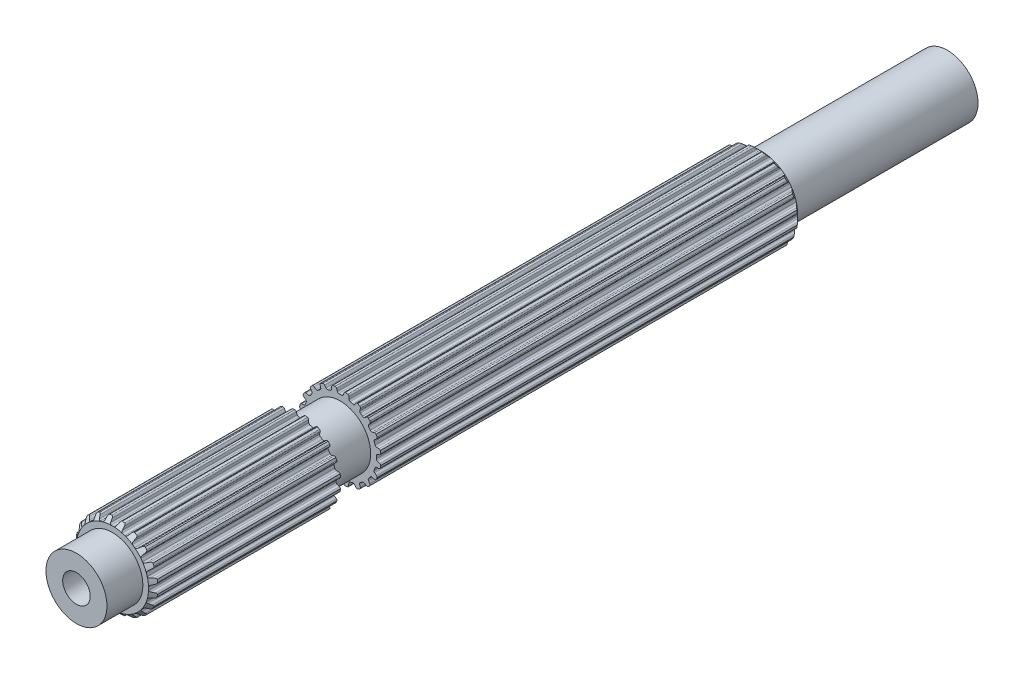
from build123d import *

# Parameters (mm, degrees)
BOSS_EXTRUDE1_DEPTH            = 15.38224
BOSS_EXTRUDE1_DEPTH_BACK       = 37.846
SKETCH2_R                      = 2.5019
BOSS_EXTRUDE2_DEPTH            = 18.32864
BOSS_EXTRUDE2_DEPTH_BACK       = 53.1114
CUT_EXTRUDE1_REACH             = 20.329
SKETCH7_R                      = 1.1303
CUT_EXTRUDE1_DIRECTION_2_REACH = 55.111
SKETCH8_R                      = 1.1303
BOSS_EXTRUDE3_DEPTH            = 8.80364
BOSS_EXTRUDE3_DEPTH_BACK       = 43.5864
SKETCH9_R                      = 6.787859549
SKETCH9_R_2                    = 2.5019
CUT_EXTRUDE2_DEPTH             = 3.302


with BuildPart() as part:
    # Sketch1 → Boss-Extrude1 (new body, two sides)
    with BuildSketch(Plane.XY) as boss_extrude1_sk:
        with BuildLine():
            Line((-0.106949245, 2.969874934), (0.106949245, 2.969874934))
            ThreePointArc((0.106949245, 2.969874934), (0.196343213, 2.986924176), (0.253739238, 3.057547504))
            Line((0.253739238, 3.057547504), (0.315888147, 3.237526941))
            ThreePointArc((0.315888147, 3.237526941), (0.359032156, 3.298322911), (0.4281449, 3.326269005))
            Line((0.4281449, 3.326269005), (0.620027588, 3.2937547))
            ThreePointArc((0.620027588, 3.2937547), (0.689621142, 3.24802576), (0.718272212, 3.169836791))
            Line((0.718272212, 3.169836791), (0.724389167, 2.979527391))
            ThreePointArc((0.724389167, 2.979527391), (0.750934762, 2.9040661), (0.816027049, 2.857568043))
            Line((0.816027049, 2.857568043), (1.019456602, 2.791469774))
            ThreePointArc((1.019456602, 2.791469774), (1.109743823, 2.780060312), (1.186154496, 2.829490741))
            Line((1.186154496, 2.829490741), (1.300878326, 2.981456288))
            ThreePointArc((1.300878326, 2.981456288), (1.360697704, 3.02594446), (1.435063648, 3.031165762))
            Line((1.435063648, 3.031165762), (1.607507455, 2.940947809))
            ThreePointArc((1.607507455, 2.940947809), (1.659563839, 2.875951412), (1.662650905, 2.792735615))
            Line((1.662650905, 2.792735615), (1.609659636, 2.609850378))
            ThreePointArc((1.609659636, 2.609850378), (1.611587176, 2.529879385), (1.659124931, 2.465542482))
            Line((1.659124931, 2.465542482), (1.832172444, 2.339816104))
            ThreePointArc((1.832172444, 2.339816104), (1.914514976, 2.301064775), (2.002460687, 2.32446371))
            Line((2.002460687, 2.32446371), (2.158529469, 2.433539921))
            ThreePointArc((2.158529469, 2.433539921), (2.229168681, 2.457365482), (2.301508367, 2.439350895))
            Line((2.301508367, 2.439350895), (2.437633293, 2.300260456))
            ThreePointArc((2.437633293, 2.300260456), (2.467056864, 2.222358901), (2.444277744, 2.14226202))
            Line((2.444277744, 2.14226202), (2.337365406, 1.984703026))
            ThreePointArc((2.337365406, 1.984703026), (2.314486209, 1.908050449), (2.339816104, 1.832172444))
            Line((2.339816104, 1.832172444), (2.465542482, 1.659124931))
            ThreePointArc((2.465542482, 1.659124931), (2.531880064, 1.596824985), (2.622752074, 1.591901975))
            Line((2.622752074, 1.591901975), (2.804888709, 1.64741171))
            ThreePointArc((2.804888709, 1.64741171), (2.879433095, 1.648242449), (2.942665411, 1.608755366))
            Line((2.942665411, 1.608755366), (3.0291466, 1.434407582))
            ThreePointArc((3.0291466, 1.434407582), (3.033057175, 1.351226417), (2.986641646, 1.282088892))
            Line((2.986641646, 1.282088892), (2.836273564, 1.165279113))
            ThreePointArc((2.836273564, 1.165279113), (2.790827206, 1.099448241), (2.791469774, 1.019456602))
            Line((2.791469774, 1.019456602), (2.857568043, 0.816027049))
            ThreePointArc((2.857568043, 0.816027049), (2.901407091, 0.736276839), (2.986310214, 0.703513784))
            Line((2.986310214, 0.703513784), (3.1766859, 0.700023363))
            ThreePointArc((3.1766859, 0.700023363), (3.247838536, 0.677777961), (3.295773863, 0.620683653))
            Line((3.295773863, 0.620683653), (3.324145932, 0.4281449))
            ThreePointArc((3.324145932, 0.4281449), (3.302160717, 0.347826477), (3.236652255, 0.29641597))
            Line((3.236652255, 0.29641597), (3.057547504, 0.231789562))
            ThreePointArc((3.057547504, 0.231789562), (2.993982591, 0.183224379), (2.969874934, 0.106949245))
            Line((2.969874934, 0.106949245), (2.969874934, -0.106949245))
            ThreePointArc((2.969874934, -0.106949245), (2.986924176, -0.196343213), (3.057547504, -0.253739238))
            Line((3.057547504, -0.253739238), (3.237526941, -0.315888147))
            ThreePointArc((3.237526941, -0.315888147), (3.298322911, -0.359032156), (3.326269005, -0.4281449))
            Line((3.326269005, -0.4281449), (3.2937547, -0.620027588))
            ThreePointArc((3.2937547, -0.620027588), (3.24802576, -0.689621142), (3.169836791, -0.718272212))
            Line((3.169836791, -0.718272212), (2.979527391, -0.724389167))
            ThreePointArc((2.979527391, -0.724389167), (2.9040661, -0.750934762), (2.857568043, -0.816027049))
            Line((2.857568043, -0.816027049), (2.791469774, -1.019456602))
            ThreePointArc((2.791469774, -1.019456602), (2.780060312, -1.109743823), (2.829490741, -1.186154496))
            Line((2.829490741, -1.186154496), (2.981456288, -1.300878326))
            ThreePointArc((2.981456288, -1.300878326), (3.02594446, -1.360697704), (3.031165762, -1.435063648))
            Line((3.031165762, -1.435063648), (2.940947809, -1.607507455))
            ThreePointArc((2.940947809, -1.607507455), (2.875951412, -1.659563839), (2.792735615, -1.662650905))
            Line((2.792735615, -1.662650905), (2.609850378, -1.609659636))
            ThreePointArc((2.609850378, -1.609659636), (2.529879385, -1.611587176), (2.465542482, -1.659124931))
            Line((2.465542482, -1.659124931), (2.339816104, -1.832172444))
            ThreePointArc((2.339816104, -1.832172444), (2.301064775, -1.914514976), (2.32446371, -2.002460687))
            Line((2.32446371, -2.002460687), (2.433539921, -2.158529469))
            ThreePointArc((2.433539921, -2.158529469), (2.457365482, -2.229168681), (2.439350895, -2.301508367))
            Line((2.439350895, -2.301508367), (2.300260456, -2.437633293))
            ThreePointArc((2.300260456, -2.437633293), (2.222358901, -2.467056864), (2.14226202, -2.444277744))
            Line((2.14226202, -2.444277744), (1.984703026, -2.337365406))
            ThreePointArc((1.984703026, -2.337365406), (1.908050449, -2.314486209), (1.832172444, -2.339816104))
            Line((1.832172444, -2.339816104), (1.659124931, -2.465542482))
            ThreePointArc((1.659124931, -2.465542482), (1.596824985, -2.531880064), (1.591901975, -2.622752074))
            Line((1.591901975, -2.622752074), (1.64741171, -2.804888709))
            ThreePointArc((1.64741171, -2.804888709), (1.648242449, -2.879433095), (1.608755366, -2.942665411))
            Line((1.608755366, -2.942665411), (1.434407582, -3.0291466))
            ThreePointArc((1.434407582, -3.0291466), (1.351226417, -3.033057175), (1.282088892, -2.986641646))
            Line((1.282088892, -2.986641646), (1.165279113, -2.836273564))
            ThreePointArc((1.165279113, -2.836273564), (1.099448241, -2.790827206), (1.019456602, -2.791469774))
            Line((1.019456602, -2.791469774), (0.816027049, -2.857568043))
            ThreePointArc((0.816027049, -2.857568043), (0.736276839, -2.901407091), (0.703513784, -2.986310214))
            Line((0.703513784, -2.986310214), (0.700023363, -3.1766859))
            ThreePointArc((0.700023363, -3.1766859), (0.677777961, -3.247838536), (0.620683653, -3.295773863))
            Line((0.620683653, -3.295773863), (0.4281449, -3.324145932))
            ThreePointArc((0.4281449, -3.324145932), (0.347826477, -3.302160717), (0.29641597, -3.236652255))
            Line((0.29641597, -3.236652255), (0.231789562, -3.057547504))
            ThreePointArc((0.231789562, -3.057547504), (0.183224379, -2.993982591), (0.106949245, -2.969874934))
            Line((0.106949245, -2.969874934), (-0.106949245, -2.969874934))
            ThreePointArc((-0.106949245, -2.969874934), (-0.196343213, -2.986924176), (-0.253739238, -3.057547504))
            Line((-0.253739238, -3.057547504), (-0.315888147, -3.237526941))
            ThreePointArc((-0.315888147, -3.237526941), (-0.359032156, -3.298322911), (-0.4281449, -3.326269005))
            Line((-0.4281449, -3.326269005), (-0.620027588, -3.2937547))
            ThreePointArc((-0.620027588, -3.2937547), (-0.689621142, -3.24802576), (-0.718272212, -3.169836791))
            Line((-0.718272212, -3.169836791), (-0.724389167, -2.979527391))
            ThreePointArc((-0.724389167, -2.979527391), (-0.750934762, -2.9040661), (-0.816027049, -2.857568043))
            Line((-0.816027049, -2.857568043), (-1.019456602, -2.791469774))
            ThreePointArc((-1.019456602, -2.791469774), (-1.109743823, -2.780060312), (-1.186154496, -2.829490741))
            Line((-1.186154496, -2.829490741), (-1.300878326, -2.981456288))
            ThreePointArc((-1.300878326, -2.981456288), (-1.360697704, -3.02594446), (-1.435063648, -3.031165762))
            Line((-1.435063648, -3.031165762), (-1.607507455, -2.940947809))
            ThreePointArc((-1.607507455, -2.940947809), (-1.659563839, -2.875951412), (-1.662650905, -2.792735615))
            Line((-1.662650905, -2.792735615), (-1.609659636, -2.609850378))
            ThreePointArc((-1.609659636, -2.609850378), (-1.611587176, -2.529879385), (-1.659124931, -2.465542482))
            Line((-1.659124931, -2.465542482), (-1.832172444, -2.339816104))
            ThreePointArc((-1.832172444, -2.339816104), (-1.914514976, -2.301064775), (-2.002460687, -2.32446371))
            Line((-2.002460687, -2.32446371), (-2.158529469, -2.433539921))
            ThreePointArc((-2.158529469, -2.433539921), (-2.229168681, -2.457365482), (-2.301508367, -2.439350895))
            Line((-2.301508367, -2.439350895), (-2.437633293, -2.300260456))
            ThreePointArc((-2.437633293, -2.300260456), (-2.467056864, -2.222358901), (-2.444277744, -2.14226202))
            Line((-2.444277744, -2.14226202), (-2.337365406, -1.984703026))
            ThreePointArc((-2.337365406, -1.984703026), (-2.314486209, -1.908050449), (-2.339816104, -1.832172444))
            Line((-2.339816104, -1.832172444), (-2.465542482, -1.659124931))
            ThreePointArc((-2.465542482, -1.659124931), (-2.531880064, -1.596824985), (-2.622752074, -1.591901975))
            Line((-2.622752074, -1.591901975), (-2.804888709, -1.64741171))
            ThreePointArc((-2.804888709, -1.64741171), (-2.879433095, -1.648242449), (-2.942665411, -1.608755366))
            Line((-2.942665411, -1.608755366), (-3.0291466, -1.434407582))
            ThreePointArc((-3.0291466, -1.434407582), (-3.033057175, -1.351226417), (-2.986641646, -1.282088892))
            Line((-2.986641646, -1.282088892), (-2.836273564, -1.165279113))
            ThreePointArc((-2.836273564, -1.165279113), (-2.790827206, -1.099448241), (-2.791469774, -1.019456602))
            Line((-2.791469774, -1.019456602), (-2.857568043, -0.816027049))
            ThreePointArc((-2.857568043, -0.816027049), (-2.901407091, -0.736276839), (-2.986310214, -0.703513784))
            Line((-2.986310214, -0.703513784), (-3.1766859, -0.700023363))
            ThreePointArc((-3.1766859, -0.700023363), (-3.247838536, -0.677777961), (-3.295773863, -0.620683653))
            Line((-3.295773863, -0.620683653), (-3.324145932, -0.4281449))
            ThreePointArc((-3.324145932, -0.4281449), (-3.302160717, -0.347826477), (-3.236652255, -0.29641597))
            Line((-3.236652255, -0.29641597), (-3.057547504, -0.231789562))
            ThreePointArc((-3.057547504, -0.231789562), (-2.993982591, -0.183224379), (-2.969874934, -0.106949245))
            Line((-2.969874934, -0.106949245), (-2.969874934, 0.106949245))
            ThreePointArc((-2.969874934, 0.106949245), (-2.986924176, 0.196343213), (-3.057547504, 0.253739238))
            Line((-3.057547504, 0.253739238), (-3.237526941, 0.315888147))
            ThreePointArc((-3.237526941, 0.315888147), (-3.298322911, 0.359032156), (-3.326269005, 0.4281449))
            Line((-3.326269005, 0.4281449), (-3.2937547, 0.620027588))
            ThreePointArc((-3.2937547, 0.620027588), (-3.24802576, 0.689621142), (-3.169836791, 0.718272212))
            Line((-3.169836791, 0.718272212), (-2.979527391, 0.724389167))
            ThreePointArc((-2.979527391, 0.724389167), (-2.9040661, 0.750934762), (-2.857568043, 0.816027049))
            Line((-2.857568043, 0.816027049), (-2.791469774, 1.019456602))
            ThreePointArc((-2.791469774, 1.019456602), (-2.780060312, 1.109743823), (-2.829490741, 1.186154496))
            Line((-2.829490741, 1.186154496), (-2.981456288, 1.300878326))
            ThreePointArc((-2.981456288, 1.300878326), (-3.02594446, 1.360697704), (-3.031165762, 1.435063648))
            Line((-3.031165762, 1.435063648), (-2.940947809, 1.607507455))
            ThreePointArc((-2.940947809, 1.607507455), (-2.875951412, 1.659563839), (-2.792735615, 1.662650905))
            Line((-2.792735615, 1.662650905), (-2.609850378, 1.609659636))
            ThreePointArc((-2.609850378, 1.609659636), (-2.529879385, 1.611587176), (-2.465542482, 1.659124931))
            Line((-2.465542482, 1.659124931), (-2.339816104, 1.832172444))
            ThreePointArc((-2.339816104, 1.832172444), (-2.301064775, 1.914514976), (-2.32446371, 2.002460687))
            Line((-2.32446371, 2.002460687), (-2.433539921, 2.158529469))
            ThreePointArc((-2.433539921, 2.158529469), (-2.457365482, 2.229168681), (-2.439350895, 2.301508367))
            Line((-2.439350895, 2.301508367), (-2.300260456, 2.437633293))
            ThreePointArc((-2.300260456, 2.437633293), (-2.222358901, 2.467056864), (-2.14226202, 2.444277744))
            Line((-2.14226202, 2.444277744), (-1.984703026, 2.337365406))
            ThreePointArc((-1.984703026, 2.337365406), (-1.908050449, 2.314486209), (-1.832172444, 2.339816104))
            Line((-1.832172444, 2.339816104), (-1.659124931, 2.465542482))
            ThreePointArc((-1.659124931, 2.465542482), (-1.596824985, 2.531880064), (-1.591901975, 2.622752074))
            Line((-1.591901975, 2.622752074), (-1.64741171, 2.804888709))
            ThreePointArc((-1.64741171, 2.804888709), (-1.648242449, 2.879433095), (-1.608755366, 2.942665411))
            Line((-1.608755366, 2.942665411), (-1.434407582, 3.0291466))
            ThreePointArc((-1.434407582, 3.0291466), (-1.351226417, 3.033057175), (-1.282088892, 2.986641646))
            Line((-1.282088892, 2.986641646), (-1.165279113, 2.836273564))
            ThreePointArc((-1.165279113, 2.836273564), (-1.099448241, 2.790827206), (-1.019456602, 2.791469774))
            Line((-1.019456602, 2.791469774), (-0.816027049, 2.857568043))
            ThreePointArc((-0.816027049, 2.857568043), (-0.736276839, 2.901407091), (-0.703513784, 2.986310214))
            Line((-0.703513784, 2.986310214), (-0.700023363, 3.1766859))
            ThreePointArc((-0.700023363, 3.1766859), (-0.677777961, 3.247838536), (-0.620683653, 3.295773863))
            Line((-0.620683653, 3.295773863), (-0.4281449, 3.324145932))
            ThreePointArc((-0.4281449, 3.324145932), (-0.347826477, 3.302160717), (-0.29641597, 3.236652255))
            Line((-0.29641597, 3.236652255), (-0.231789562, 3.057547504))
            ThreePointArc((-0.231789562, 3.057547504), (-0.183224379, 2.993982591), (-0.106949245, 2.969874934))
        make_face()
    extrude(amount=BOSS_EXTRUDE1_DEPTH)
    extrude(boss_extrude1_sk.sketch, amount=-BOSS_EXTRUDE1_DEPTH_BACK)

    # Sketch2 → Boss-Extrude2 (add, two sides)
    with BuildSketch(Plane.XY) as boss_extrude2_sk:
        Circle(SKETCH2_R)
    extrude(amount=BOSS_EXTRUDE2_DEPTH)
    extrude(boss_extrude2_sk.sketch, amount=-BOSS_EXTRUDE2_DEPTH_BACK)

    # Sketch3 → Cut-Revolve1 (revolve, cut)
    with BuildSketch(Plane(origin=(0, 0, 0), x_dir=(0, 0, -1), z_dir=(1, 0, 0))):
        Polygon((-14.251015505, 4.101099429), (-15.38224, 2.969874934), (-15.38224, 4.101099429), align=None)
        Polygon((37.846, 34.559869155), (37.846, 2.969874934), (22.051002889, 18.764872045), align=None)
    revolve(axis=Axis((0, 0, 14.360793934), (0, 0, -1)), mode=Mode.SUBTRACT)

    # Cut-Extrude1: up to this face of the body (flat: up to its plane)
    cut_extrude1_end = Plane(part.part.faces().sort_by_distance((0, 0, 18.32864))[0])
    # Sketch7 → Cut-Extrude1 (cut, up to the picked face)
    with BuildSketch(Plane.XY, mode=Mode.PRIVATE) as cut_extrude1_sk1:
        Circle(SKETCH7_R)
    cut_extrude1_tool1 = split(extrude(cut_extrude1_sk1.sketch, amount=CUT_EXTRUDE1_REACH, mode=Mode.PRIVATE), bisect_by=cut_extrude1_end, keep=Keep.BOTH, mode=Mode.PRIVATE)
    add(cut_extrude1_tool1.solids().sort_by_distance((0, 0, 0))[0], mode=Mode.SUBTRACT)

    # Cut-Extrude1 direction 2: up to this face of the body (flat: up to its plane)
    cut_extrude1_direction_2_end = Plane(part.part.faces().sort_by_distance((0, 0, -53.1114))[0])
    # Sketch7 → Cut-Extrude1 direction 2 (cut, up to the picked face)
    with BuildSketch(Plane.XY, mode=Mode.PRIVATE) as cut_extrude1_direction_2_sk1:
        Circle(SKETCH7_R)
    cut_extrude1_direction_2_tool1 = split(extrude(cut_extrude1_direction_2_sk1.sketch, amount=-CUT_EXTRUDE1_DIRECTION_2_REACH, mode=Mode.PRIVATE), bisect_by=cut_extrude1_direction_2_end, keep=Keep.BOTH, mode=Mode.PRIVATE)
    add(cut_extrude1_direction_2_tool1.solids().sort_by_distance((0, 0, 0))[0], mode=Mode.SUBTRACT)

    # Sketch8 → Boss-Extrude3 (add, two sides)
    with BuildSketch(Plane.XY) as boss_extrude3_sk:
        Circle(SKETCH8_R)
    extrude(amount=BOSS_EXTRUDE3_DEPTH)
    extrude(boss_extrude3_sk.sketch, amount=-BOSS_EXTRUDE3_DEPTH_BACK)

    # Sketch9 → Cut-Extrude2 (cut)
    with BuildSketch(Plane.XY):
        Circle(SKETCH9_R)
        Circle(SKETCH9_R_2, mode=Mode.SUBTRACT)
    extrude(amount=-CUT_EXTRUDE2_DEPTH, mode=Mode.SUBTRACT)


solid = part.part
